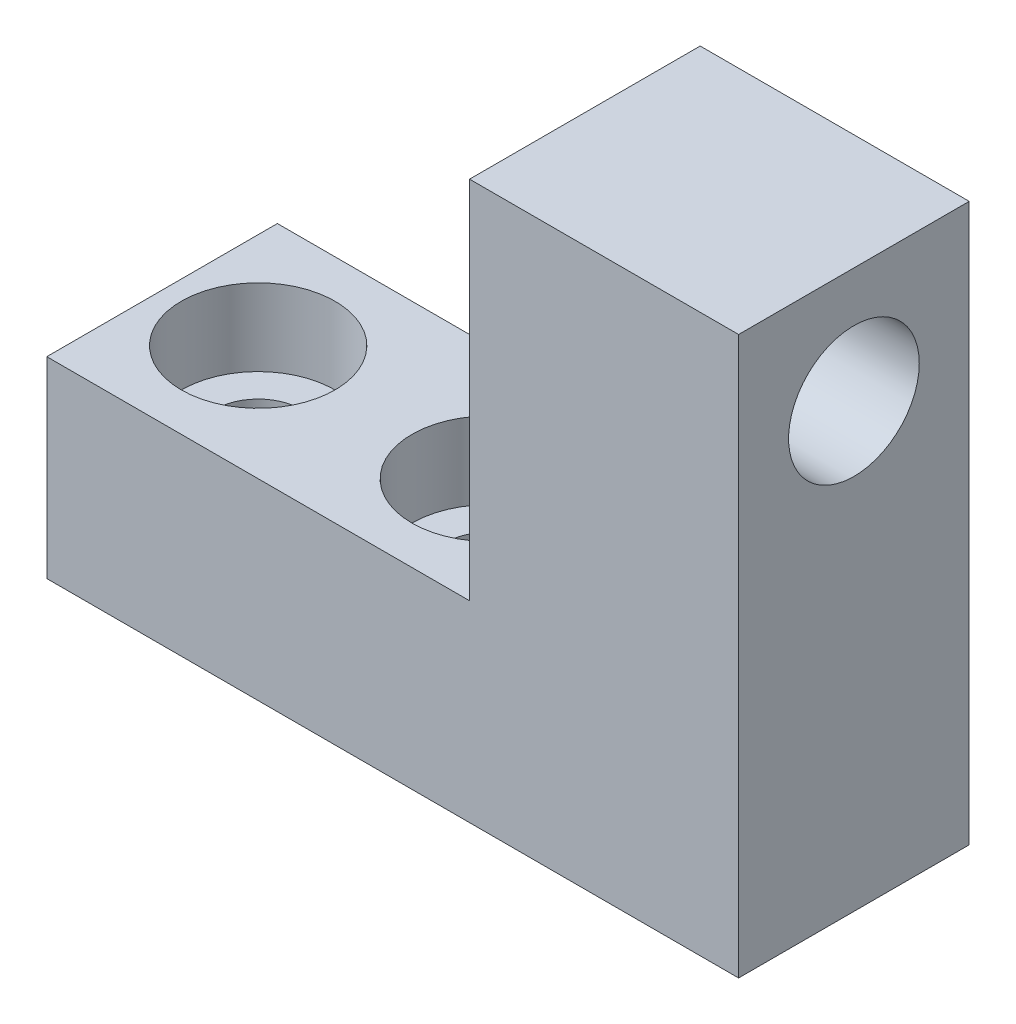
from build123d import *

# Parameters (mm, degrees)
SKETCH1_W             = 36
SKETCH1_H             = 10
BOSS_EXTRUDE1_DEPTH   = 12
SKETCH2_W             = 14
SKETCH2_H             = 12
BOSS_EXTRUDE2_DEPTH   = 19
SKETCH3_R             = 2.25
CUT_EXTRUDE1_DEPTH    = 11
SKETCH4_R             = 4
CUT_EXTRUDE2_DEPTH    = 4
M8_TAPPED_HOLE1_D     = 6.8
M8_TAPPED_HOLE1_DEPTH = 19.75
M8_TAPPED_HOLE1_TIP   = 2.042926105


with BuildPart() as part:
    # Sketch1 → Boss-Extrude1 (new body)
    with BuildSketch(Plane.XY):
        with Locations((9.722605043, -1.956268222)):
            Rectangle(SKETCH1_W, SKETCH1_H)
    extrude(amount=BOSS_EXTRUDE1_DEPTH)

    # Sketch2 → Boss-Extrude2 (add)
    with BuildSketch(Plane(origin=(0, 3.043731778, 0), x_dir=(1, 0, 0), z_dir=(0, 1, 0))):
        with Locations((20.722605043, -6)):
            Rectangle(SKETCH2_W, SKETCH2_H)
    extrude(amount=BOSS_EXTRUDE2_DEPTH)

    # Sketch3 → Cut-Extrude1 (cut, through all)
    with BuildSketch(Plane(origin=(0, 3.043731778, 0), x_dir=(1, 0, 0), z_dir=(0, 1, 0))):
        with Locations((-3.277394957, -6)):
            Circle(SKETCH3_R)
        with Locations((8.722605043, -6)):
            Circle(SKETCH3_R)
    extrude(amount=-CUT_EXTRUDE1_DEPTH, mode=Mode.SUBTRACT)

    # Sketch4 → Cut-Extrude2 (cut)
    with BuildSketch(Plane(origin=(0, 3.043731778, 0), x_dir=(1, 0, 0), z_dir=(0, 1, 0))):
        with Locations((-3.277394957, -6)):
            Circle(SKETCH4_R)
        with Locations((8.722605043, -6)):
            Circle(SKETCH4_R)
    extrude(amount=-CUT_EXTRUDE2_DEPTH, mode=Mode.SUBTRACT)

    # M8 Tapped Hole1
    with Locations(Plane(origin=(27.722605043, 0, 0), x_dir=(0, 0, -1), z_dir=(1, 0, 0))):
        with Locations((-6, 16.043731778)):
            Hole(M8_TAPPED_HOLE1_D / 2, depth=M8_TAPPED_HOLE1_DEPTH)
            with Locations((0, 0, -(M8_TAPPED_HOLE1_DEPTH + M8_TAPPED_HOLE1_TIP / 2))):  # 118° drill point
                Cone(0, M8_TAPPED_HOLE1_D / 2, M8_TAPPED_HOLE1_TIP, mode=Mode.SUBTRACT)


solid = part.part
